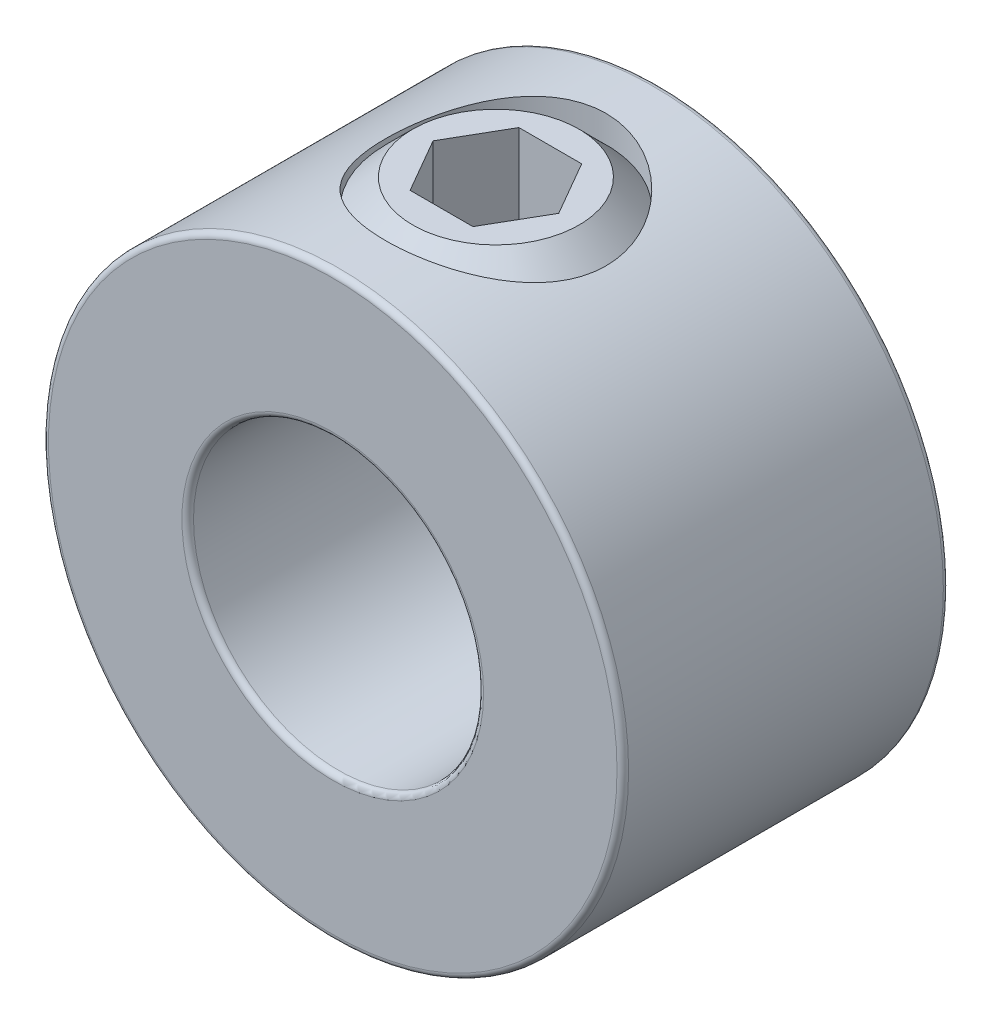
from build123d import *

# Parameters (mm, degrees)
SKETCH1_R          = 6.35
SKETCH1_R_2        = 3.175
EXTRUDE1_DEPTH     = 3.571875
SKETCH2_R          = 2.413
CUT_EXTRUDE1_DEPTH = 7.35
FILLET1_R          = 0.127
CUT_EXTRUDE2_DEPTH = 2.38125


with BuildPart() as part:
    # Sketch1 → Extrude1 (new body, symmetric)
    with BuildSketch(Plane.XY):
        Circle(SKETCH1_R)
        Circle(SKETCH1_R_2, mode=Mode.SUBTRACT)
    extrude(amount=EXTRUDE1_DEPTH, both=True)

    # Sketch2 → Cut-Extrude1 (cut, through all)
    with BuildSketch(Plane(origin=(41.275, 0, 0), x_dir=(0, 0, -1), z_dir=(0, -1, 0))):
        with Locations((0, -41.275)):
            Circle(SKETCH2_R)
    extrude(amount=-CUT_EXTRUDE1_DEPTH, mode=Mode.SUBTRACT)

    # Fillet1
    fillet1_edges = [part.edges().sort_by_distance(p)[0] for p in [
        (-6.35, 0, -3.571875),
        (-6.35, 0, 3.571875),
        (-3.175, 0, -3.571875),
        (-3.175, 0, 3.571875),
    ]]
    fillet(fillet1_edges, radius=FILLET1_R)


with BuildPart() as body_2:
    # Sketch3 → Revolve1 (revolve)
    with BuildSketch(Plane.XY):
        Polygon((-1.819751616, 3.175), (-0.71189806, 3.175), (0, 3.88689806), (0, 6.35), (-1.819751616, 6.35), (-2.413, 5.756751616), (-2.413, 3.768248384), align=None)
    revolve(axis=Axis((0, 3.175, 0), (0, -1, 0)))

    # Sketch4 → Cut-Extrude2 (cut)
    with BuildSketch(Plane(origin=(3.3734375, 6.35, 0), x_dir=(0, 0, -1), z_dir=(0, -1, 0))):
        Polygon((0, -1.998622171), (-1.190625, -2.686029836), (-1.190625, -4.060845164), (0, -4.748252829), (1.190625, -4.060845164), (1.190625, -2.686029836), align=None)
    extrude(amount=CUT_EXTRUDE2_DEPTH, mode=Mode.SUBTRACT)


solid = Compound([part.part, body_2.part])
